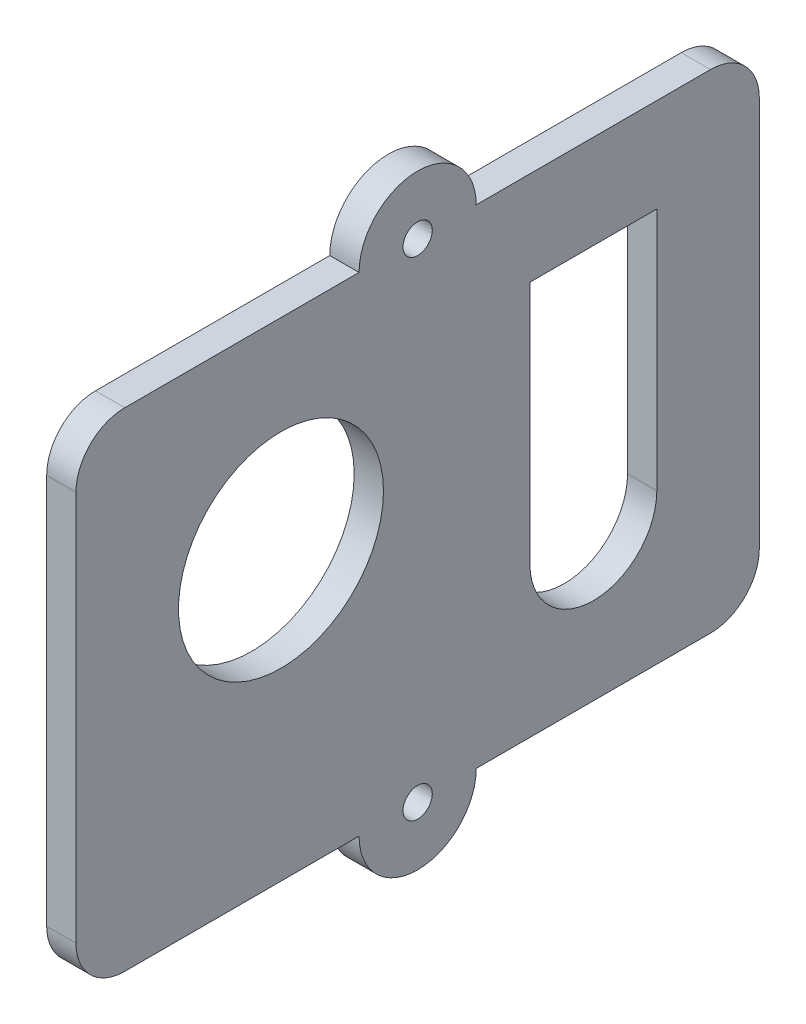
from build123d import *

# Parameters (mm, degrees)
BOSS_EXTRUDE1_DEPTH = 3
SKETCH2_R           = 1.5
SKETCH2_R_2         = 10.5
CUT_EXTRUDE1_DEPTH  = 4


with BuildPart() as part:
    # Sketch1 → Boss-Extrude1 (new body)
    with BuildSketch(Plane(origin=(0, 0, 0), x_dir=(0, 0, -1), z_dir=(1, 0, 0))):
        with BuildLine():
            Line((35, -5.382304056), (35, 34.617695944))
            ThreePointArc((35, 34.617695944), (33.535533906, 38.15322985), (30, 39.617695944))
            Line((30, 39.617695944), (6, 39.617695944))
            ThreePointArc((6, 39.617695944), (0, 45.617695944), (-6, 39.617695944))
            Line((-6, 39.617695944), (-30, 39.617695944))
            ThreePointArc((-30, 39.617695944), (-33.535533906, 38.15322985), (-35, 34.617695944))
            Line((-35, 34.617695944), (-35, -5.382304056))
            ThreePointArc((-35, -5.382304056), (-33.535533906, -8.917837962), (-30, -10.382304056))
            Line((-30, -10.382304056), (-6, -10.382304056))
            ThreePointArc((-6, -10.382304056), (0, -16.382304056), (6, -10.382304056))
            Line((6, -10.382304056), (30, -10.382304056))
            ThreePointArc((30, -10.382304056), (33.535533906, -8.917837962), (35, -5.382304056))
        make_face()
    extrude(amount=BOSS_EXTRUDE1_DEPTH)

    # Sketch2 → Cut-Extrude1 (cut, through all)
    with BuildSketch(Plane(origin=(3, 0, 0), x_dir=(0, 0, -1), z_dir=(1, 0, 0))):
        with Locations((0, 39.617695944)):
            Circle(SKETCH2_R)
        with Locations((0, -10.382304056)):
            Circle(SKETCH2_R)
        with Locations((-14, 19)):
            Circle(SKETCH2_R_2)
        with BuildLine():
            Line((11.5, 30), (24.5, 30))
            Line((24.5, 30), (24.5, 5))
            ThreePointArc((24.5, 5), (18, -1.5), (11.5, 5))
            Line((11.5, 5), (11.5, 30))
        make_face()
    extrude(amount=-CUT_EXTRUDE1_DEPTH, mode=Mode.SUBTRACT)


solid = part.part
